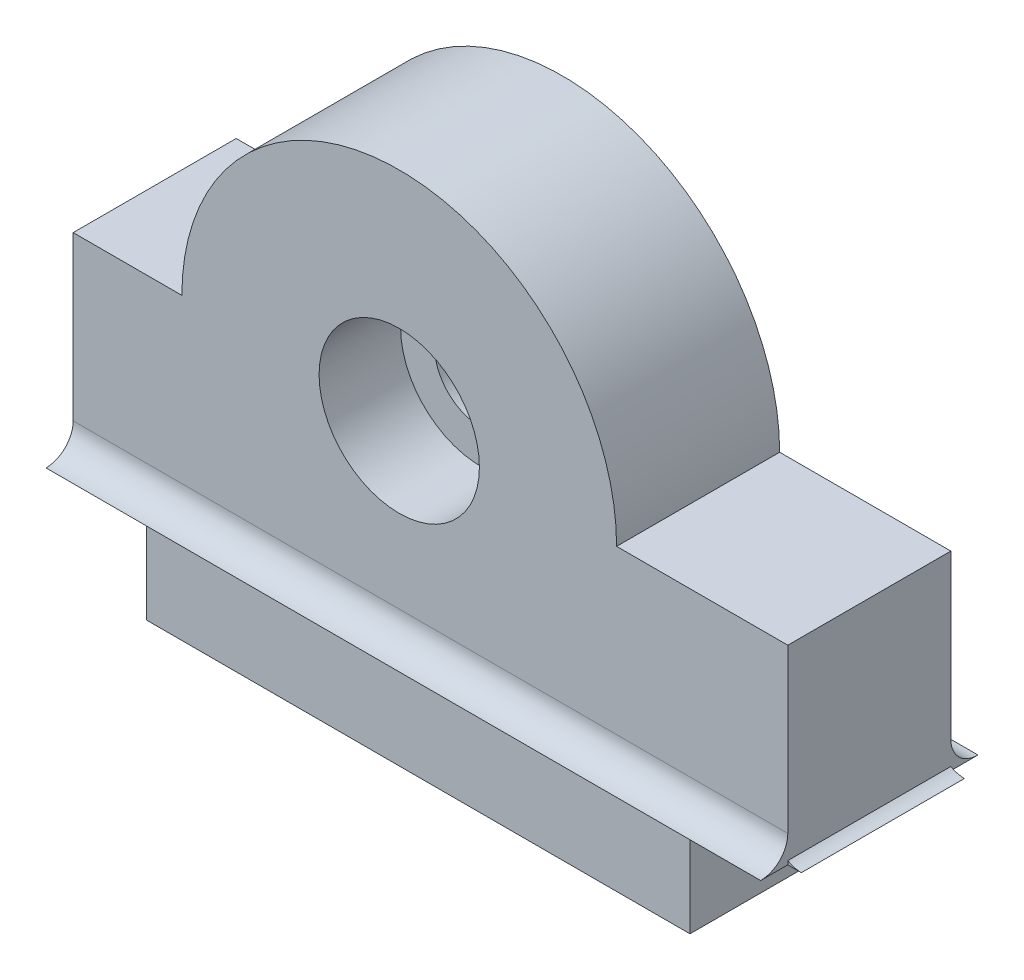
from build123d import *

# Parameters (mm, degrees)
SKETCH1_R           = 2.95
BOSS_EXTRUDE1_DEPTH = 6
BOSS_EXTRUDE2_DEPTH = 26.3
BOSS_EXTRUDE3_DEPTH = 6
SKETCH5_R           = 2.95
SKETCH5_R_2         = 1.7
BOSS_EXTRUDE4_DEPTH = 3


with BuildPart() as part:
    # Sketch1 → Boss-Extrude1 (new body)
    with BuildSketch(Plane.XY):
        with BuildLine():
            Line((0, 0), (20, 0))
            Line((20, 0), (20, 4))
            Line((20, 4), (23.6, 4))
            Line((23.6, 4), (23.6, 11))
            Line((23.6, 11), (17.3, 11))
            ThreePointArc((17.3, 11), (9.3, 19), (1.3, 11))
            Line((1.3, 11), (-2.7, 11))
            Line((-2.7, 11), (-2.7, 4))
            Line((-2.7, 4), (0, 4))
            Line((0, 4), (0, 0))
        make_face()
        with Locations((9.3, 11)):
            Circle(SKETCH1_R, mode=Mode.SUBTRACT)
    extrude(amount=BOSS_EXTRUDE1_DEPTH)

    # Sketch2 → Boss-Extrude2 (add)
    with BuildSketch(Plane.ZY.offset(2.7)):
        with BuildLine():
            Line((6, 4), (6, 5))
            ThreePointArc((6, 5), (6.292893219, 4.292893219), (7, 4))
            Line((7, 4), (6, 4))
        make_face()
        with BuildLine():
            Line((0, 4), (-1, 4))
            ThreePointArc((-1, 4), (-0.292893219, 4.292893219), (0, 5))
            Line((0, 5), (0, 4))
        make_face()
    extrude(amount=-BOSS_EXTRUDE2_DEPTH)

    # Sketch4 → Boss-Extrude3 (add)
    with BuildSketch(Plane.XY.offset(6)):
        with BuildLine():
            Line((23.1, 4), (23.1, 5))
            ThreePointArc((23.1, 5), (23.392893219, 4.292893219), (24.1, 4))
            Line((24.1, 4), (23.1, 4))
        make_face()
        with BuildLine():
            Line((-1.5, 4), (-2.5, 4))
            ThreePointArc((-2.5, 4), (-1.792893219, 4.292893219), (-1.5, 5))
            Line((-1.5, 5), (-1.5, 4))
        make_face()
    extrude(amount=-BOSS_EXTRUDE3_DEPTH)

    # Sketch5 → Boss-Extrude4 (add)
    with BuildSketch(Plane(origin=(0, 0, 0), x_dir=(-1, 0, 0), z_dir=(0, 0, -1))):
        with Locations((-9.3, 11)):
            Circle(SKETCH5_R)
        with Locations((-9.3, 11)):
            Circle(SKETCH5_R_2, mode=Mode.SUBTRACT)
    extrude(amount=-BOSS_EXTRUDE4_DEPTH)


solid = part.part
